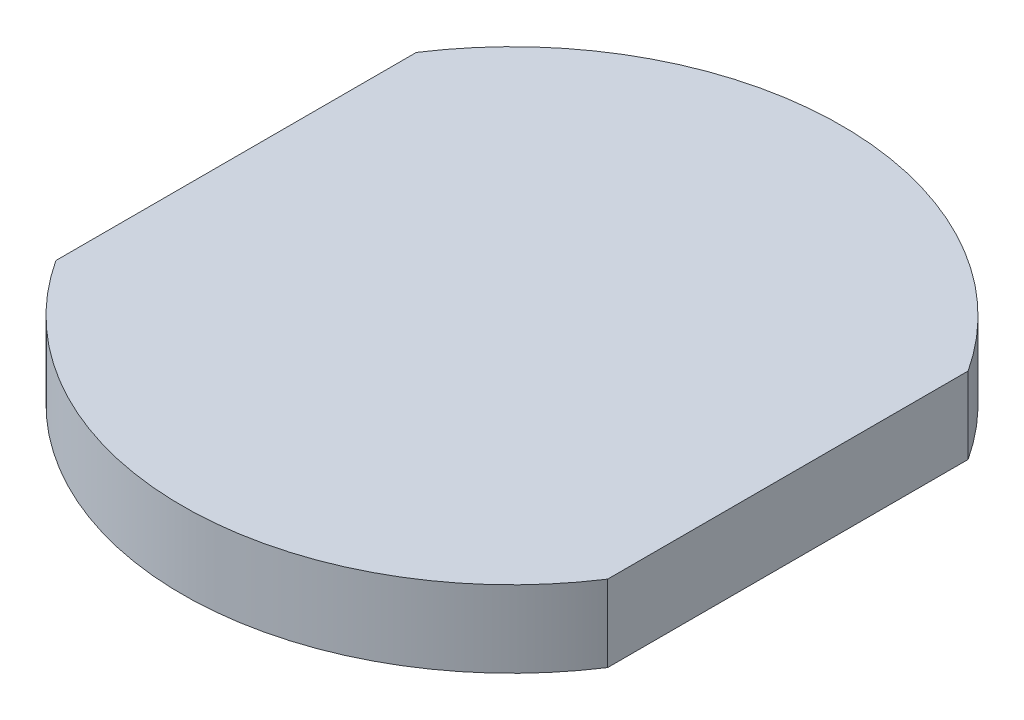
from build123d import *

# Parameters (mm, degrees)
Y_KSEKLIK_EKSTR_ZYON1_DEPTH = 5


with BuildPart() as part:
    # Çizim1 → Yükseklik-Ekstrüzyon1 (new body)
    with BuildSketch(Plane(origin=(0, 0, 0), x_dir=(1, 0, 0), z_dir=(0, 1, 0))):
        with BuildLine():
            Line((-18, -11.757976016), (-18, 11.757976016))
            ThreePointArc((-18, 11.757976016), (0, 21.5), (18, 11.757976016))
            Line((18, 11.757976016), (18, -11.757976016))
            ThreePointArc((18, -11.757976016), (0, -21.5), (-18, -11.757976016))
        make_face()
    extrude(amount=-Y_KSEKLIK_EKSTR_ZYON1_DEPTH)


solid = part.part
